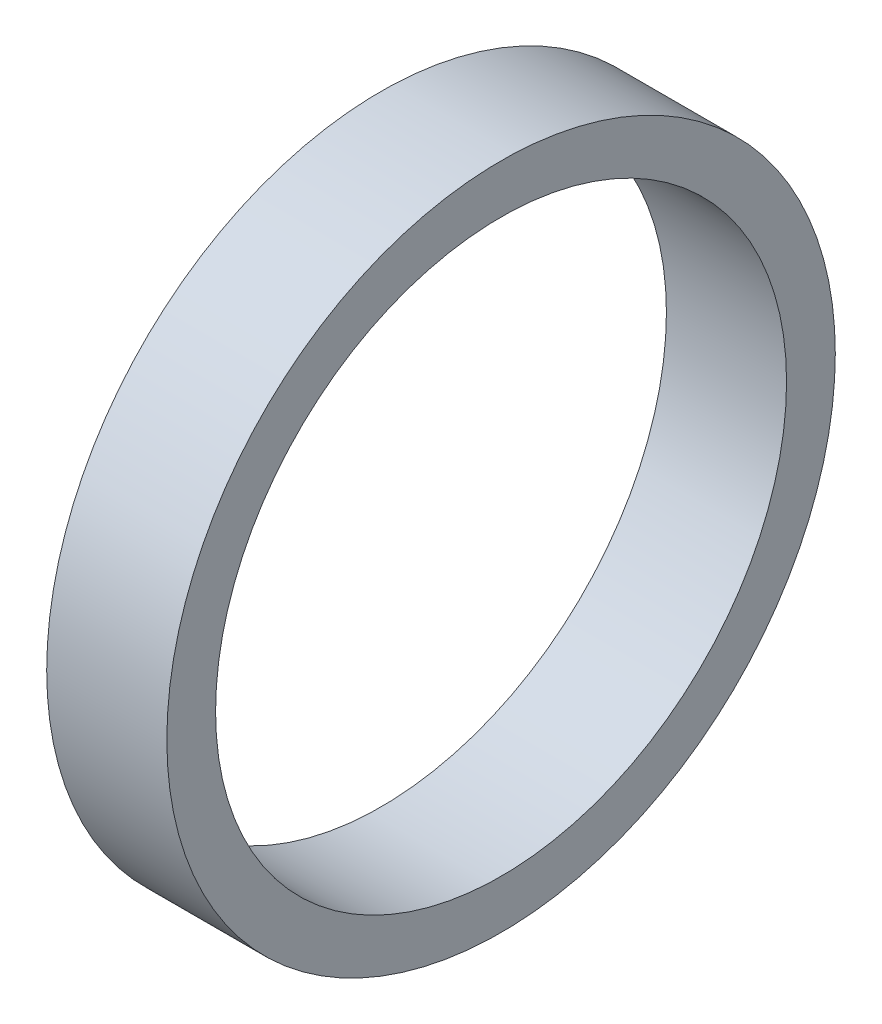
from build123d import *

# Parameters (mm, degrees)
SKETCH1_R           = 18
SKETCH1_R_2         = 15.375
BOSS_EXTRUDE1_DEPTH = 6.47


with BuildPart() as part:
    # Sketch1 → Boss-Extrude1 (new body)
    with BuildSketch(Plane(origin=(0, 0, 0), x_dir=(0, 0, -1), z_dir=(1, 0, 0))):
        Circle(SKETCH1_R)
        Circle(SKETCH1_R_2, mode=Mode.SUBTRACT)
    extrude(amount=BOSS_EXTRUDE1_DEPTH)


solid = part.part
